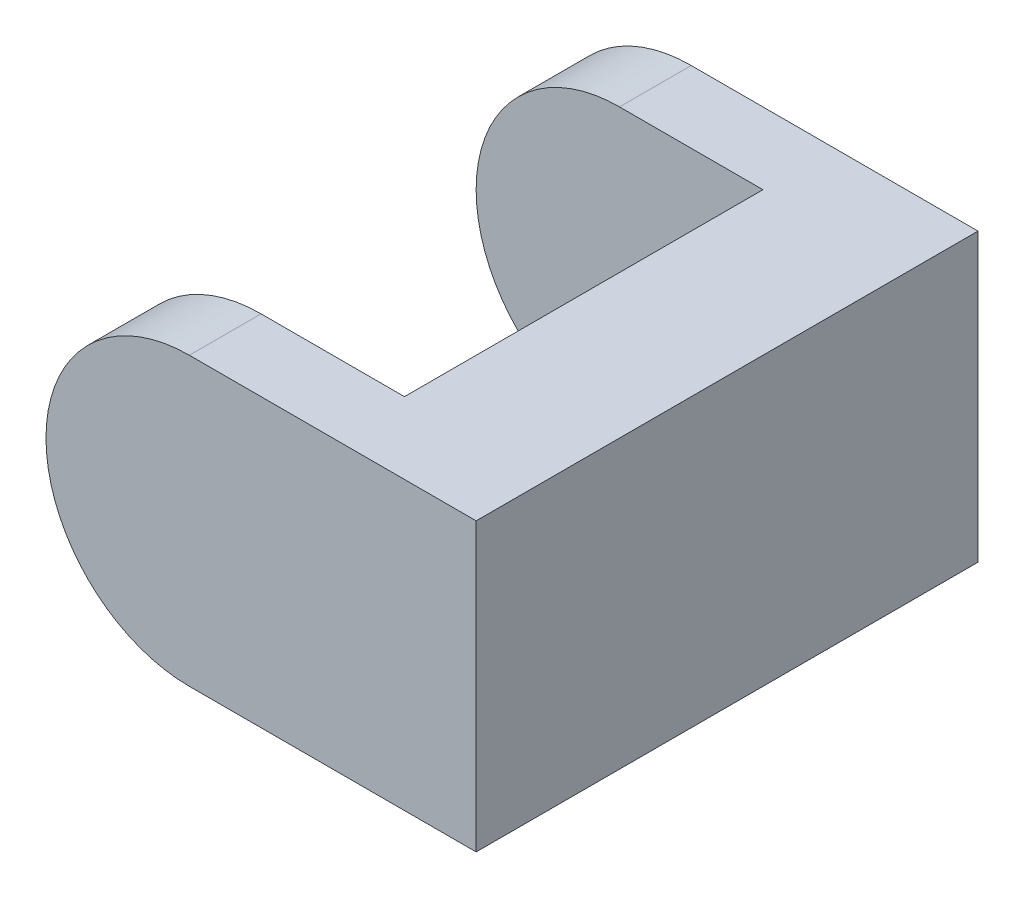
from build123d import *

# Parameters (mm, degrees)
ESTRUSIONE_ESTRUSIONE1_DEPTH = 140
SCHIZZO2_W                   = 160
SCHIZZO2_H                   = 100
TAGLIO_ESTRUSIONE1_DEPTH     = 140


with BuildPart() as part:
    # Schizzo1 → Estrusione-Estrusione1 (new body)
    with BuildSketch(Plane.XY):
        with BuildLine():
            Line((40, 40), (-40, 40))
            ThreePointArc((-40, 40), (-80, 0), (-40, -40))
            Line((-40, -40), (40, -40))
            Line((40, -40), (40, 40))
        make_face()
    extrude(amount=ESTRUSIONE_ESTRUSIONE1_DEPTH)

    # Schizzo2 → Taglio-Estrusione1 (cut)
    with BuildSketch(Plane(origin=(0, 40, 0), x_dir=(1, 0, 0), z_dir=(0, 1, 0))):
        with Locations((-80, -70)):
            Rectangle(SCHIZZO2_W, SCHIZZO2_H)
    extrude(amount=-TAGLIO_ESTRUSIONE1_DEPTH, mode=Mode.SUBTRACT)


solid = part.part
